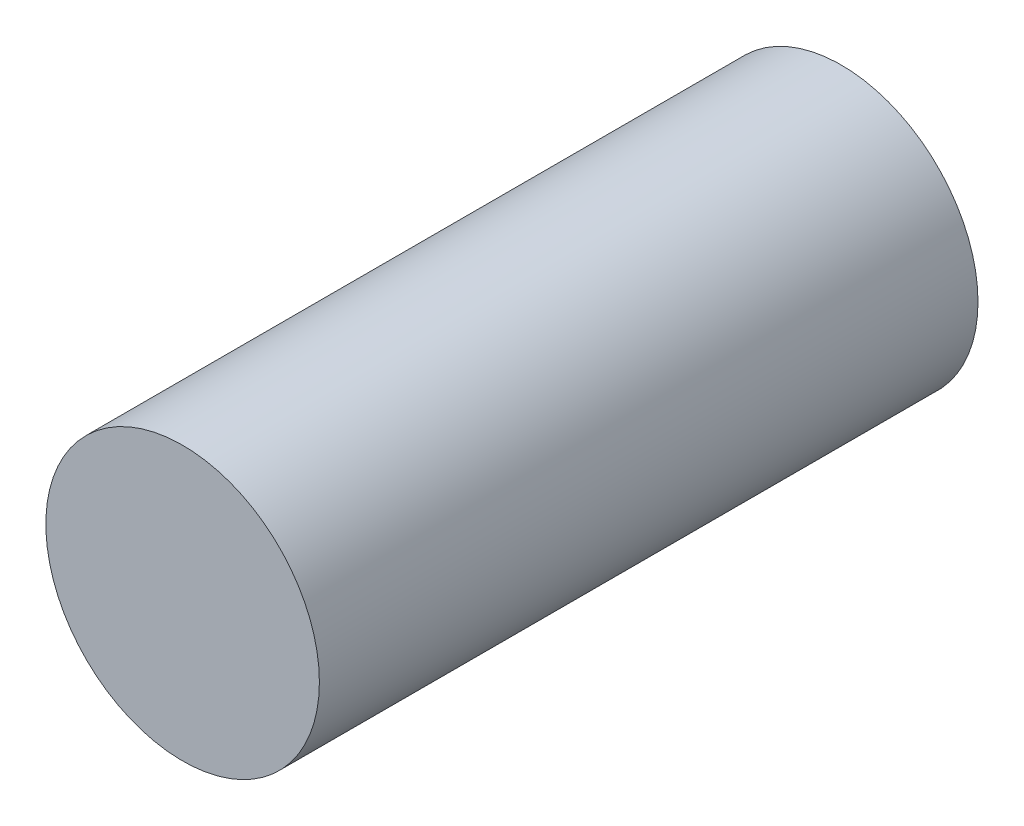
from build123d import *

# Parameters (mm, degrees)
SKETCH_1_R      = 623
EXTRUDE_1_DEPTH = 3000


with BuildPart() as part:
    # Эскиз1 → Вытянуть1 (new body)
    with BuildSketch(Plane.XY):
        with Locations((689, 689)):
            Circle(SKETCH_1_R)
    extrude(amount=-EXTRUDE_1_DEPTH)


solid = part.part
